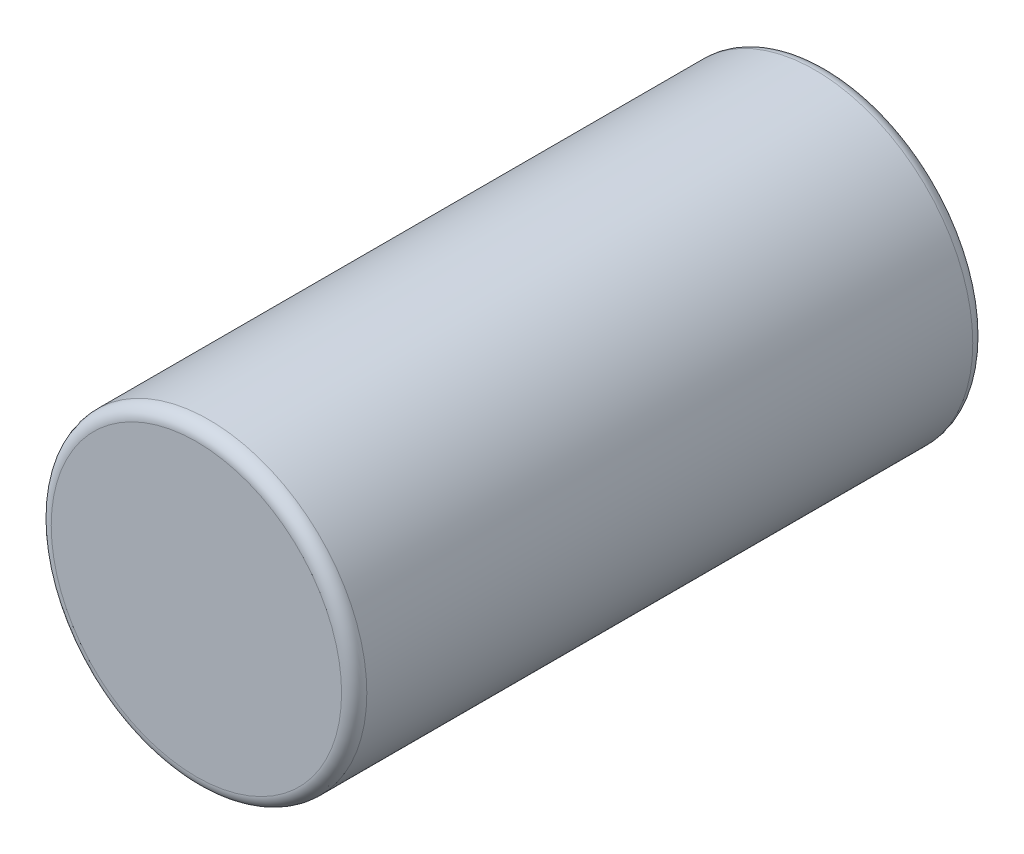
from build123d import *

# Parameters (mm, degrees)
SKETCH1_R           = 3.175
BOSS_EXTRUDE1_DEPTH = 12.7
FILLET1_R           = 0.254


with BuildPart() as part:
    # Sketch1 → Boss-Extrude1 (new body)
    with BuildSketch(Plane.XY):
        Circle(SKETCH1_R)
    extrude(amount=BOSS_EXTRUDE1_DEPTH)

    # Fillet1
    fillet1_edges = [part.edges().sort_by_distance(p)[0] for p in [
        (-3.175, 0, 0),
        (-3.175, 0, 12.7),
    ]]
    fillet(fillet1_edges, radius=FILLET1_R)


solid = part.part
